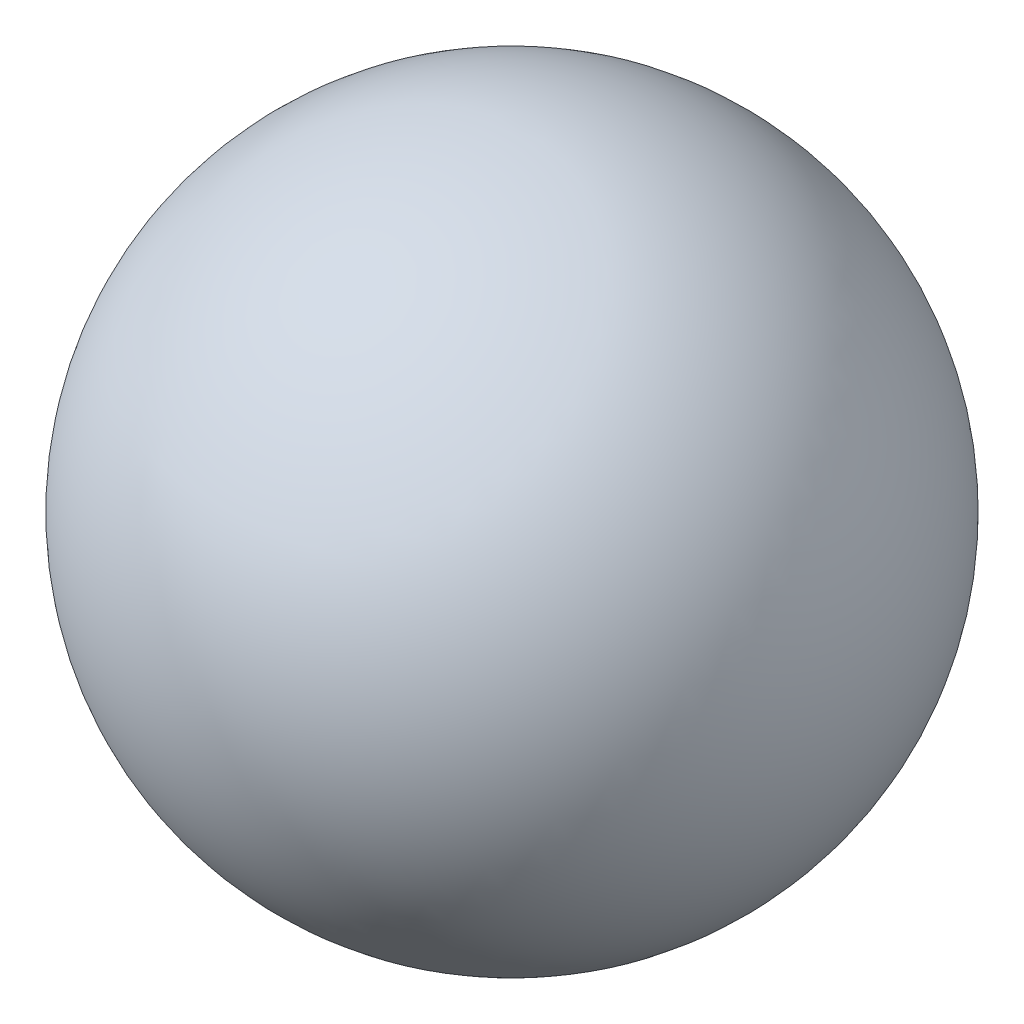
from build123d import *


with BuildPart() as part:
    # Sketch1 one side → Revolve1 (revolve)
    with BuildSketch(Plane.XY):
        with BuildLine():
            Line((0, -127), (0, 127))
            ThreePointArc((0, 127), (-127, 0), (0, -127))
        make_face()
    revolve(axis=Axis((0, 0, 0), (0, 1, 0)))


solid = part.part
